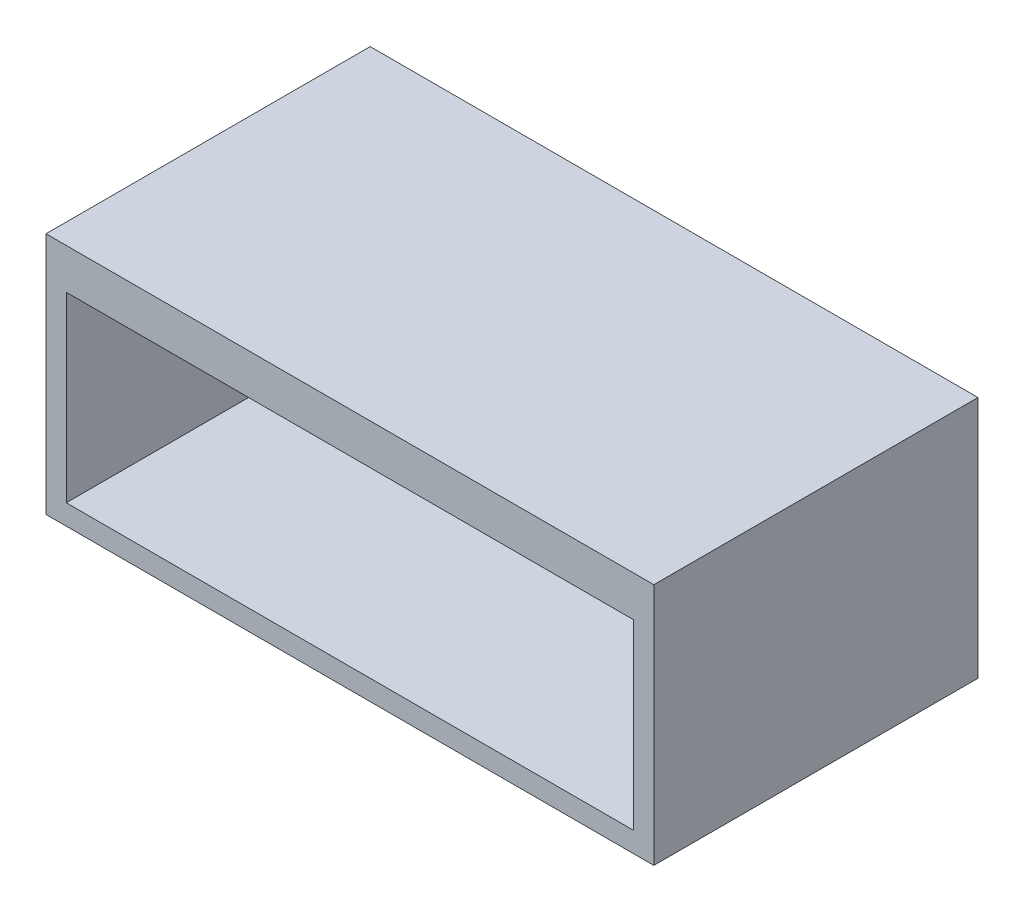
from build123d import *

# Parameters (mm, degrees)
SKETCH1_W                 = 150
SKETCH1_H                 = 80
BOSS_EXTRUDE1_DEPTH       = 60
SHELL1_T                  = -5
SHELL1_THICKNESS_2_FACE_W = 75
SHELL1_THICKNESS_2_FACE_H = 140
SHELL1_THICKNESS_2_DEPTH  = 5


with BuildPart() as part:
    # Sketch1 → Boss-Extrude1 (new body)
    with BuildSketch(Plane(origin=(0, 0, 0), x_dir=(1, 0, 0), z_dir=(0, 1, 0))):
        with Locations((75, 40)):
            Rectangle(SKETCH1_W, SKETCH1_H)
    extrude(amount=BOSS_EXTRUDE1_DEPTH)

    # Shell1
    shell1_openings = [part.faces().sort_by_distance(p)[0] for p in [
        (75, 30, 0),
    ]]
    offset(amount=SHELL1_T, openings=shell1_openings, kind=Kind.INTERSECTION)

    # Shell1 thickness 2 face (on inner face of the shell) → Shell1 thickness 2 (add)
    with BuildSketch(Plane(origin=(75, 55, -37.5), x_dir=(0, 0, 1), z_dir=(0, 1, 0))):
        Rectangle(SHELL1_THICKNESS_2_FACE_W, SHELL1_THICKNESS_2_FACE_H)
    extrude(amount=-SHELL1_THICKNESS_2_DEPTH)


solid = part.part
